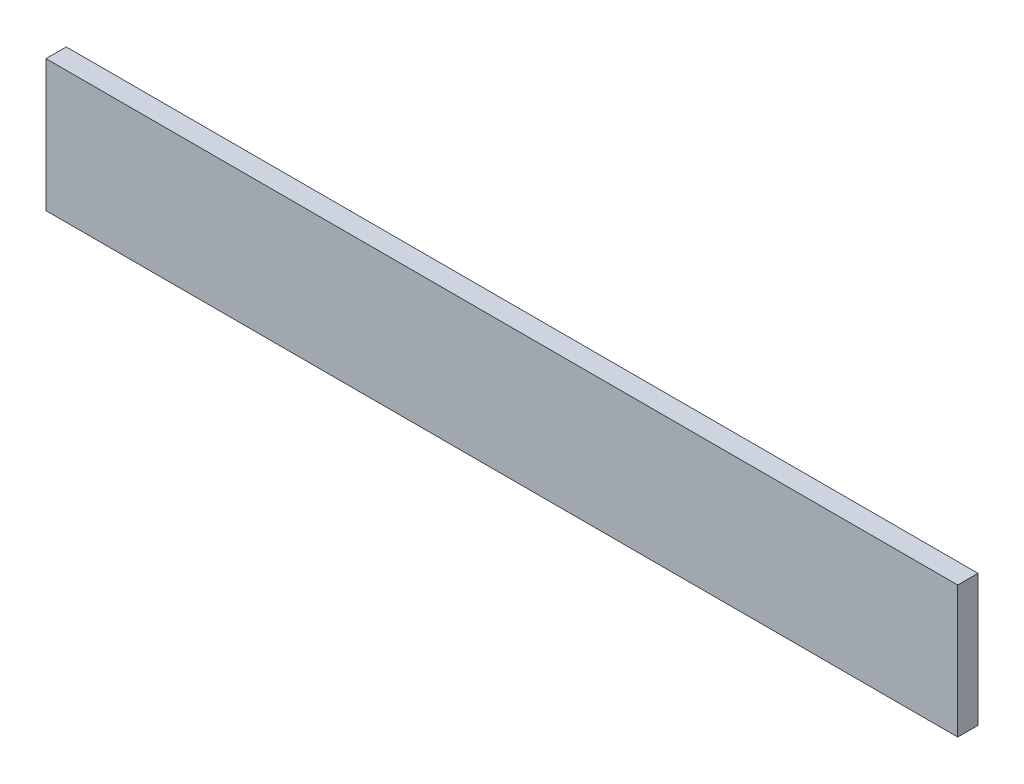
from build123d import *

# Parameters (mm, degrees)
SKETCH1_W           = 450
SKETCH1_H           = 65
BOSS_EXTRUDE1_DEPTH = 10


with BuildPart() as part:
    # Sketch1 → Boss-Extrude1 (new body)
    with BuildSketch(Plane.XY):
        with Locations((225, 32.5)):
            Rectangle(SKETCH1_W, SKETCH1_H)
    extrude(amount=BOSS_EXTRUDE1_DEPTH)


solid = part.part
